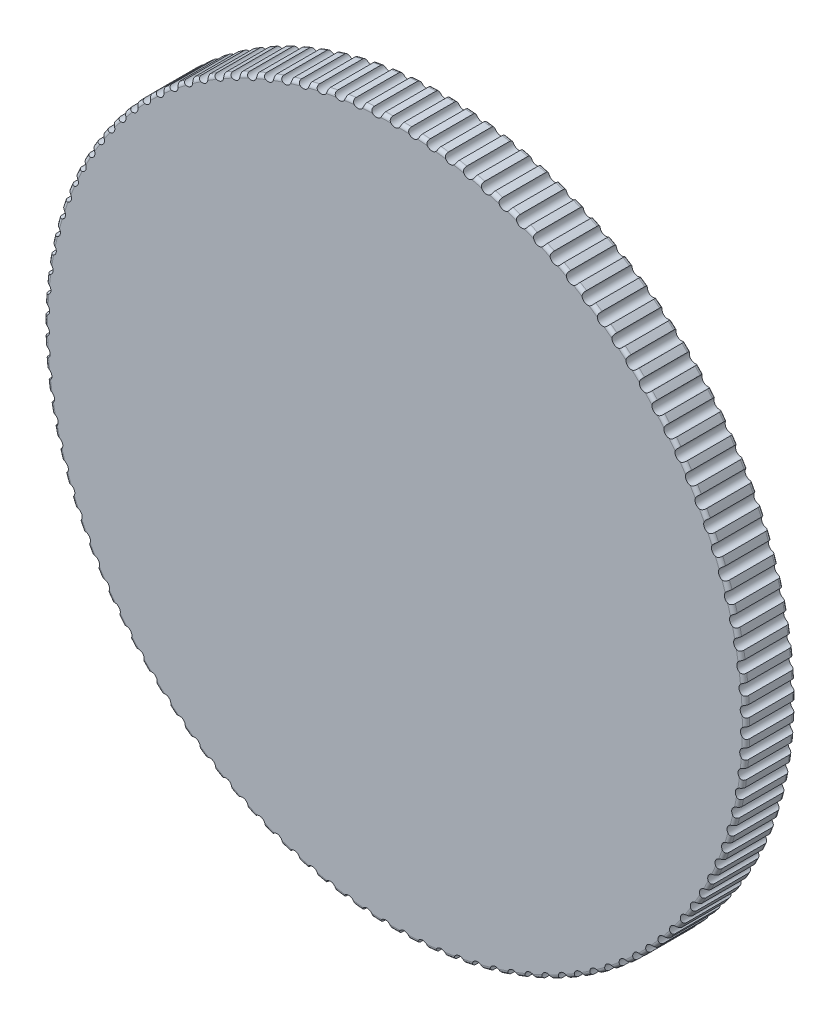
from build123d import *

# Parameters (mm, degrees)
SKETCH1_R          = 12.1031
EXTRUDE1_DEPTH     = 1.7272
FILLET1_R          = 0.127
SKETCH2_R          = 0.1905
CUT_EXTRUDE1_DEPTH = 2.7272


with BuildPart() as part:
    # Sketch1 → Extrude1 (new body)
    with BuildSketch(Plane.XY):
        Circle(SKETCH1_R)
    extrude(amount=EXTRUDE1_DEPTH)

    # Fillet1
    fillet1_edges = [part.edges().sort_by_distance(p)[0] for p in [
        (-12.1031, 0, 0),
        (-12.1031, 0, 1.7272),
    ]]
    fillet(fillet1_edges, radius=FILLET1_R)

    # Sketch2 → Cut-Extrude1 (cut, through all)
    with BuildSketch(Plane.XY.offset(1.7272)):
        with Locations((0, 12.1031)):
            Circle(SKETCH2_R)
        with Locations((0.638745304, 12.086233245)):
            Circle(SKETCH2_R)
        with Locations((1.27571031, 12.03567999)):
            Circle(SKETCH2_R)
        with Locations((1.909119683, 11.951581136)):
            Circle(SKETCH2_R)
        with Locations((2.537207996, 11.834171082)):
            Circle(SKETCH2_R)
        with Locations((3.158224656, 11.68377707)):
            Circle(SKETCH2_R)
        with Locations((3.770438778, 11.500818277)):
            Circle(SKETCH2_R)
        with Locations((4.37214401, 11.28580464)):
            Circle(SKETCH2_R)
        with Locations((4.961663293, 11.039335441)):
            Circle(SKETCH2_R)
        with Locations((5.53735353, 10.762097634)):
            Circle(SKETCH2_R)
        with Locations((6.09761017, 10.454863932)):
            Circle(SKETCH2_R)
        with Locations((6.640871676, 10.118490648)):
            Circle(SKETCH2_R)
        with Locations((7.165623883, 9.753915316)):
            Circle(SKETCH2_R)
        with Locations((7.67040421, 9.362154072)):
            Circle(SKETCH2_R)
        with Locations((8.153805745, 8.944298826)):
            Circle(SKETCH2_R)
        with Locations((8.61448116, 8.501514215)):
            Circle(SKETCH2_R)
        with Locations((9.051146472, 8.035034359)):
            Circle(SKETCH2_R)
        with Locations((9.462584615, 7.546159421)):
            Circle(SKETCH2_R)
        with Locations((9.847648838, 7.036251983)):
            Circle(SKETCH2_R)
        with Locations((10.205265897, 6.506733249)):
            Circle(SKETCH2_R)
        with Locations((10.53443905, 5.959079083)):
            Circle(SKETCH2_R)
        with Locations((10.834250832, 5.394815894)):
            Circle(SKETCH2_R)
        with Locations((11.103865613, 4.815516386)):
            Circle(SKETCH2_R)
        with Locations((11.342531929, 4.222795169)):
            Circle(SKETCH2_R)
        with Locations((11.549584575, 3.618304266)):
            Circle(SKETCH2_R)
        with Locations((11.724446457, 3.003728499)):
            Circle(SKETCH2_R)
        with Locations((11.866630203, 2.380780802)):
            Circle(SKETCH2_R)
        with Locations((11.975739523, 1.751197443)):
            Circle(SKETCH2_R)
        with Locations((12.051470309, 1.116733181)):
            Circle(SKETCH2_R)
        with Locations((12.093611486, 0.479156385)):
            Circle(SKETCH2_R)
        with Locations((12.102045598, -0.159755907)):
            Circle(SKETCH2_R)
        with Locations((12.076749139, -0.79822293)):
            Circle(SKETCH2_R)
        with Locations((12.017792614, -1.434465163)):
            Circle(SKETCH2_R)
        with Locations((11.925340345, -2.066709284)):
            Circle(SKETCH2_R)
        with Locations((11.799650014, -2.693193116)):
            Circle(SKETCH2_R)
        with Locations((11.641071942, -3.312170535)):
            Circle(SKETCH2_R)
        with Locations((11.450048114, -3.921916341)):
            Circle(SKETCH2_R)
        with Locations((11.227110949, -4.520731063)):
            Circle(SKETCH2_R)
        with Locations((10.972881812, -5.106945696)):
            Circle(SKETCH2_R)
        with Locations((10.688069285, -5.678926356)):
            Circle(SKETCH2_R)
        with Locations((10.373467193, -6.23507883)):
            Circle(SKETCH2_R)
        with Locations((10.029952386, -6.77385302)):
            Circle(SKETCH2_R)
        with Locations((9.658482303, -7.293747268)):
            Circle(SKETCH2_R)
        with Locations((9.260092298, -7.793312533)):
            Circle(SKETCH2_R)
        with Locations((8.835892755, -8.271156439)):
            Circle(SKETCH2_R)
        with Locations((8.387065994, -8.725947148)):
            Circle(SKETCH2_R)
        with Locations((7.914862976, -9.156417077)):
            Circle(SKETCH2_R)
        with Locations((7.420599814, -9.56136643)):
            Circle(SKETCH2_R)
        with Locations((6.905654111, -9.939666539)):
            Circle(SKETCH2_R)
        with Locations((6.371461111, -10.290263015)):
            Circle(SKETCH2_R)
        with Locations((5.819509705, -10.612178683)):
            Circle(SKETCH2_R)
        with Locations((5.251338283, -10.904516305)):
            Circle(SKETCH2_R)
        with Locations((4.668530439, -11.166461085)):
            Circle(SKETCH2_R)
        with Locations((4.072710563, -11.397282934)):
            Circle(SKETCH2_R)
        with Locations((3.465539312, -11.596338512)):
            Circle(SKETCH2_R)
        with Locations((2.848708982, -11.763073015)):
            Circle(SKETCH2_R)
        with Locations((2.223938789, -11.897021723)):
            Circle(SKETCH2_R)
        with Locations((1.59297008, -11.997811298)):
            Circle(SKETCH2_R)
        with Locations((0.957561477, -12.065160821)):
            Circle(SKETCH2_R)
        with Locations((0.319483979, -12.098882576)):
            Circle(SKETCH2_R)
        with Locations((-0.319483979, -12.098882576)):
            Circle(SKETCH2_R)
        with Locations((-0.957561477, -12.065160821)):
            Circle(SKETCH2_R)
        with Locations((-1.59297008, -11.997811298)):
            Circle(SKETCH2_R)
        with Locations((-2.223938789, -11.897021723)):
            Circle(SKETCH2_R)
        with Locations((-2.848708982, -11.763073015)):
            Circle(SKETCH2_R)
        with Locations((-3.465539312, -11.596338512)):
            Circle(SKETCH2_R)
        with Locations((-4.072710563, -11.397282934)):
            Circle(SKETCH2_R)
        with Locations((-4.668530439, -11.166461085)):
            Circle(SKETCH2_R)
        with Locations((-5.251338283, -10.904516305)):
            Circle(SKETCH2_R)
        with Locations((-5.819509705, -10.612178683)):
            Circle(SKETCH2_R)
        with Locations((-6.371461111, -10.290263015)):
            Circle(SKETCH2_R)
        with Locations((-6.905654111, -9.939666539)):
            Circle(SKETCH2_R)
        with Locations((-7.420599814, -9.56136643)):
            Circle(SKETCH2_R)
        with Locations((-7.914862976, -9.156417077)):
            Circle(SKETCH2_R)
        with Locations((-8.387065994, -8.725947148)):
            Circle(SKETCH2_R)
        with Locations((-8.835892755, -8.271156439)):
            Circle(SKETCH2_R)
        with Locations((-9.260092298, -7.793312533)):
            Circle(SKETCH2_R)
        with Locations((-9.658482303, -7.293747268)):
            Circle(SKETCH2_R)
        with Locations((-10.029952386, -6.77385302)):
            Circle(SKETCH2_R)
        with Locations((-10.373467193, -6.23507883)):
            Circle(SKETCH2_R)
        with Locations((-10.688069285, -5.678926356)):
            Circle(SKETCH2_R)
        with Locations((-10.972881812, -5.106945696)):
            Circle(SKETCH2_R)
        with Locations((-11.227110949, -4.520731063)):
            Circle(SKETCH2_R)
        with Locations((-11.450048114, -3.921916341)):
            Circle(SKETCH2_R)
        with Locations((-11.641071942, -3.312170535)):
            Circle(SKETCH2_R)
        with Locations((-11.799650014, -2.693193116)):
            Circle(SKETCH2_R)
        with Locations((-11.925340345, -2.066709284)):
            Circle(SKETCH2_R)
        with Locations((-12.017792614, -1.434465163)):
            Circle(SKETCH2_R)
        with Locations((-12.076749139, -0.79822293)):
            Circle(SKETCH2_R)
        with Locations((-12.102045598, -0.159755907)):
            Circle(SKETCH2_R)
        with Locations((-12.093611486, 0.479156385)):
            Circle(SKETCH2_R)
        with Locations((-12.051470309, 1.116733181)):
            Circle(SKETCH2_R)
        with Locations((-11.975739523, 1.751197443)):
            Circle(SKETCH2_R)
        with Locations((-11.866630203, 2.380780802)):
            Circle(SKETCH2_R)
        with Locations((-11.724446457, 3.003728499)):
            Circle(SKETCH2_R)
        with Locations((-11.549584575, 3.618304266)):
            Circle(SKETCH2_R)
        with Locations((-11.342531929, 4.222795169)):
            Circle(SKETCH2_R)
        with Locations((-11.103865613, 4.815516386)):
            Circle(SKETCH2_R)
        with Locations((-10.834250832, 5.394815894)):
            Circle(SKETCH2_R)
        with Locations((-10.53443905, 5.959079083)):
            Circle(SKETCH2_R)
        with Locations((-10.205265897, 6.506733249)):
            Circle(SKETCH2_R)
        with Locations((-9.847648838, 7.036251983)):
            Circle(SKETCH2_R)
        with Locations((-9.462584615, 7.546159421)):
            Circle(SKETCH2_R)
        with Locations((-9.051146472, 8.035034359)):
            Circle(SKETCH2_R)
        with Locations((-8.61448116, 8.501514215)):
            Circle(SKETCH2_R)
        with Locations((-8.153805745, 8.944298826)):
            Circle(SKETCH2_R)
        with Locations((-7.67040421, 9.362154072)):
            Circle(SKETCH2_R)
        with Locations((-7.165623883, 9.753915316)):
            Circle(SKETCH2_R)
        with Locations((-6.640871676, 10.118490648)):
            Circle(SKETCH2_R)
        with Locations((-6.09761017, 10.454863932)):
            Circle(SKETCH2_R)
        with Locations((-5.53735353, 10.762097634)):
            Circle(SKETCH2_R)
        with Locations((-4.961663293, 11.039335441)):
            Circle(SKETCH2_R)
        with Locations((-4.37214401, 11.28580464)):
            Circle(SKETCH2_R)
        with Locations((-3.770438778, 11.500818277)):
            Circle(SKETCH2_R)
        with Locations((-3.158224656, 11.68377707)):
            Circle(SKETCH2_R)
        with Locations((-2.537207996, 11.834171082)):
            Circle(SKETCH2_R)
        with Locations((-1.909119683, 11.951581136)):
            Circle(SKETCH2_R)
        with Locations((-1.27571031, 12.03567999)):
            Circle(SKETCH2_R)
        with Locations((-0.638745304, 12.086233245)):
            Circle(SKETCH2_R)
    extrude(amount=-CUT_EXTRUDE1_DEPTH, mode=Mode.SUBTRACT)


solid = part.part
